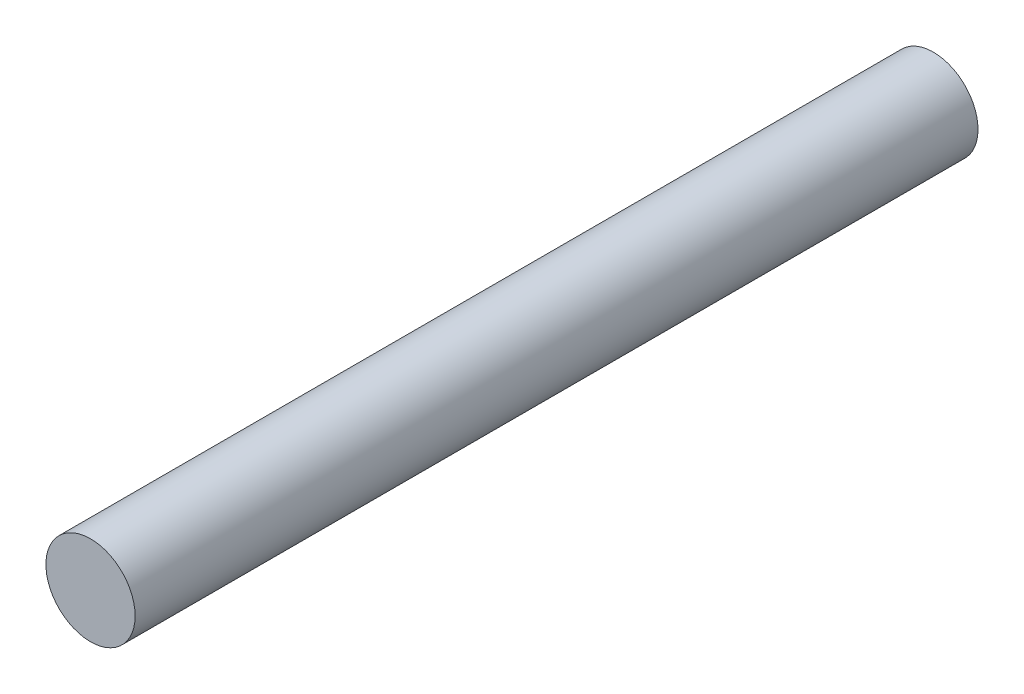
from build123d import *

# Parameters (mm, degrees)
SKETCH1_R           = 24.875
BOSS_EXTRUDE1_DEPTH = 470.02


with BuildPart() as part:
    # Sketch1 → Boss-Extrude1 (new body)
    with BuildSketch(Plane.XY):
        Circle(SKETCH1_R)
    extrude(amount=BOSS_EXTRUDE1_DEPTH)


solid = part.part
